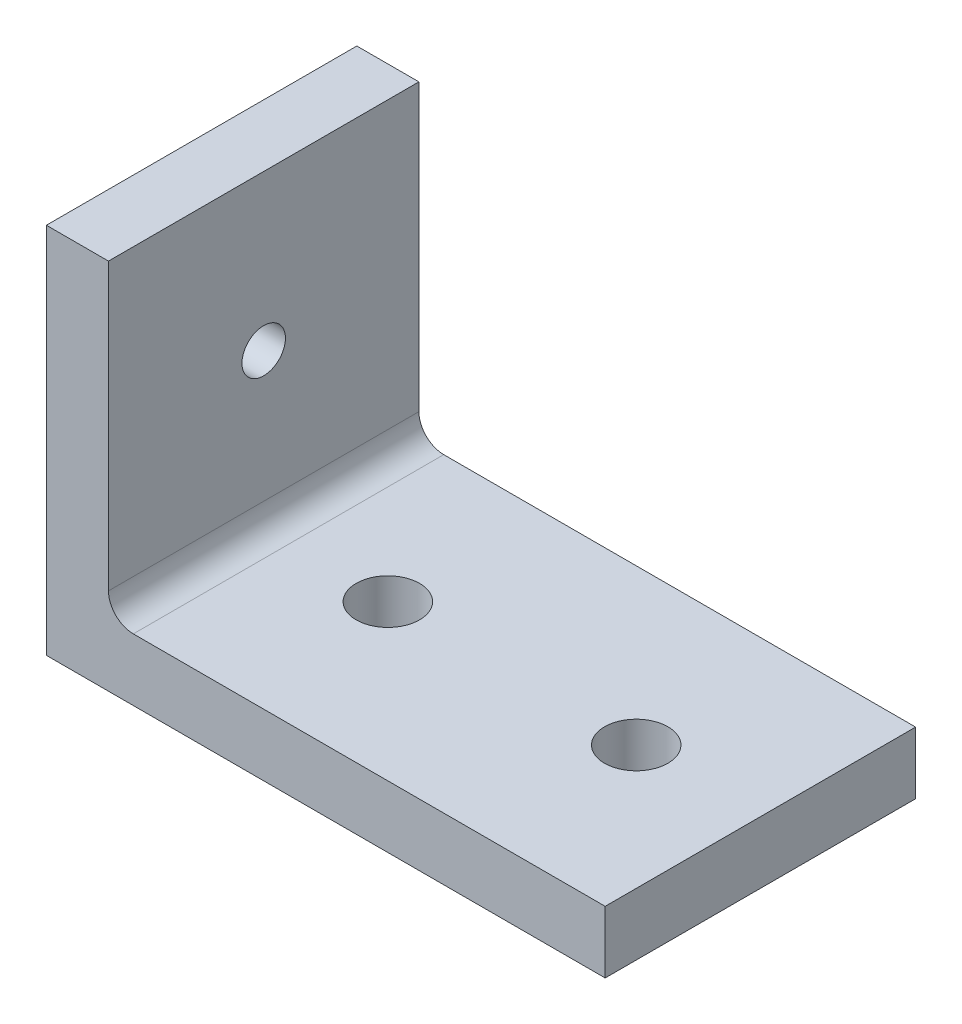
from build123d import *

# Parameters (mm, degrees)
BOSS_EXTRUDE1_DEPTH = 25
SKETCH2_R           = 1.75
CUT_EXTRUDE1_DEPTH  = 25
FILLET1_R           = 2
SKETCH4_R           = 2.55
CUT_EXTRUDE2_DEPTH  = 25


with BuildPart() as part:
    # Sketch1 → Boss-Extrude1 (new body)
    with BuildSketch(Plane.XY):
        Polygon((0, 30), (0, 0), (45, 0), (45, 5), (5, 5), (5, 30), align=None)
    extrude(amount=BOSS_EXTRUDE1_DEPTH)

    # Sketch2 → Cut-Extrude1 (cut)
    with BuildSketch(Plane(origin=(5, 0, 0), x_dir=(0, 0, -1), z_dir=(1, 0, 0))):
        with Locations((-12.5, 17.5)):
            Circle(SKETCH2_R)
    extrude(amount=-CUT_EXTRUDE1_DEPTH, mode=Mode.SUBTRACT)

    # Fillet1
    fillet1_edges = [part.edges().sort_by_distance(p)[0] for p in [
        (5, 5, 12.5),
    ]]
    fillet(fillet1_edges, radius=FILLET1_R)

    # Sketch4 → Cut-Extrude2 (cut)
    with BuildSketch(Plane(origin=(0, 5, 0), x_dir=(1, 0, 0), z_dir=(0, 1, 0))):
        with Locations((35, -12.5)):
            Circle(SKETCH4_R)
        with Locations((15, -12.5)):
            Circle(SKETCH4_R)
    extrude(amount=-CUT_EXTRUDE2_DEPTH, mode=Mode.SUBTRACT)


solid = part.part
